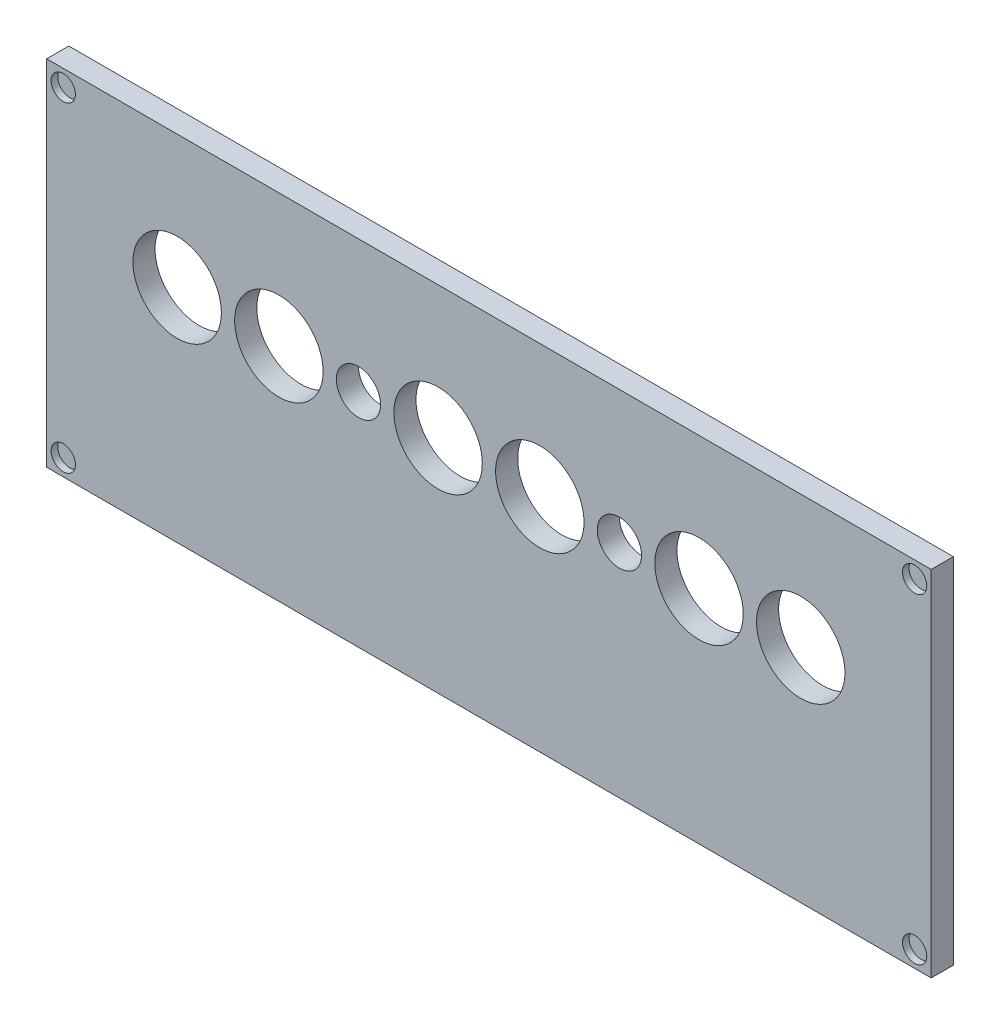
from build123d import *

# Parameters (mm, degrees)
CROQUIS1_W              = 200
CROQUIS1_H              = 80
SALIENTE_EXTRUIR1_DEPTH = 5
CROQUIS2_R              = 2.75
CORTAR_EXTRUIR1_DEPTH   = 1.5
CROQUIS4_R              = 10
CROQUIS4_R_2            = 5
CORTAR_EXTRUIR3_DEPTH   = 5


with BuildPart() as part:
    # Croquis1 → Saliente-Extruir1 (new body)
    with BuildSketch(Plane.XY):
        Rectangle(CROQUIS1_W, CROQUIS1_H)
    extrude(amount=SALIENTE_EXTRUIR1_DEPTH)

    # Croquis2 → Cortar-Extruir1 (cut)
    with BuildSketch(Plane.XY.offset(5)):
        with Locations((-96.25, 36.25)):
            Circle(CROQUIS2_R)
        with Locations((96.25, 36.25)):
            Circle(CROQUIS2_R)
        with Locations((96.25, -36.25)):
            Circle(CROQUIS2_R)
        with Locations((-96.25, -36.25)):
            Circle(CROQUIS2_R)
    extrude(amount=-CORTAR_EXTRUIR1_DEPTH, mode=Mode.SUBTRACT)

    # Croquis4 → Cortar-Extruir3 (cut)
    with BuildSketch(Plane.XY.offset(5)):
        with Locations((-70.5, 10)):
            Circle(CROQUIS4_R)
        with Locations((-47.5, 10)):
            Circle(CROQUIS4_R)
        with Locations((-29.5, 10)):
            Circle(CROQUIS4_R_2)
        with Locations((-11.5, 10)):
            Circle(CROQUIS4_R)
        with Locations((11.5, 10)):
            Circle(CROQUIS4_R)
        with Locations((29.5, 10)):
            Circle(CROQUIS4_R_2)
        with Locations((47.5, 10)):
            Circle(CROQUIS4_R)
        with Locations((70.5, 10)):
            Circle(CROQUIS4_R)
    extrude(amount=-CORTAR_EXTRUIR3_DEPTH, mode=Mode.SUBTRACT)


solid = part.part
